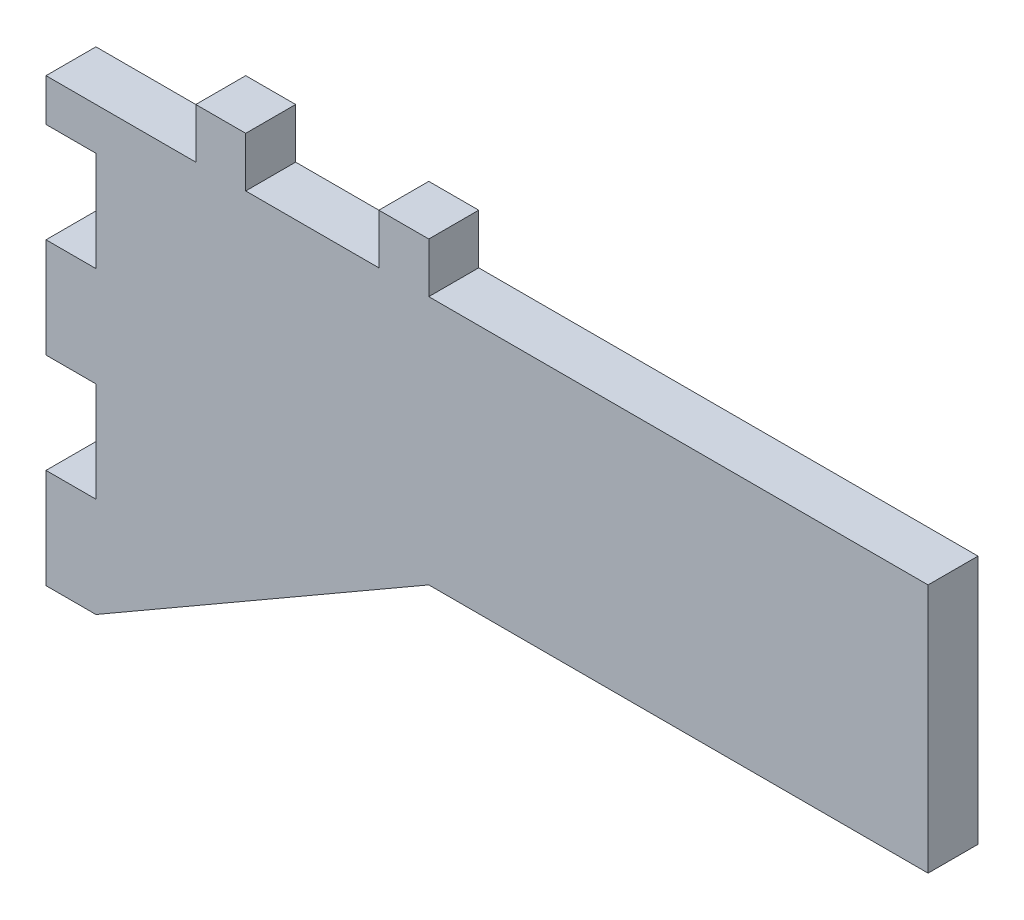
from build123d import *

# Parameters (mm, degrees)
BOSS_EXTRUDE1_DEPTH = 3
SKETCH2_W           = 3
SKETCH2_H           = 2.54
SKETCH2_H_2         = 6
BOSS_EXTRUDE2_DEPTH = 3


with BuildPart() as part:
    # Sketch1 → Boss-Extrude1 (new body)
    with BuildSketch(Plane.XY):
        Polygon((-3, 0), (-11, 0), (-11, 3), (-14, 3), (-14, 0), (-20, 0), (-20, -26.54), (0, -15), (30, -15), (30, 0), (0, 0), (0, 3), (-3, 3), align=None)
    extrude(amount=BOSS_EXTRUDE1_DEPTH)

    # Sketch2 → Boss-Extrude2 (add)
    with BuildSketch(Plane.XY.offset(3)):
        with Locations((-21.5, -1.27)):
            Rectangle(SKETCH2_W, SKETCH2_H)
        with Locations((-21.5, -11.54)):
            Rectangle(SKETCH2_W, SKETCH2_H_2)
        with Locations((-21.5, -23.54)):
            Rectangle(SKETCH2_W, SKETCH2_H_2)
    extrude(amount=-BOSS_EXTRUDE2_DEPTH)


solid = part.part
